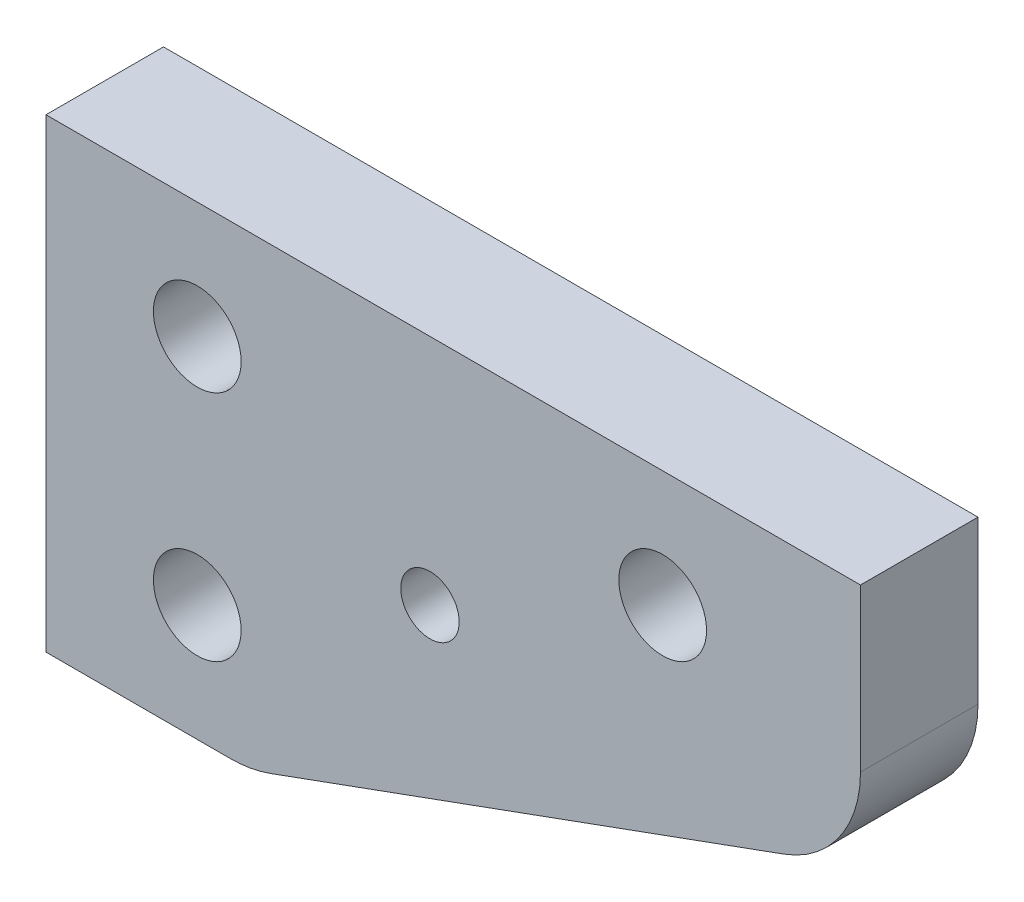
from build123d import *

# Parameters (mm, degrees)
SKETCH1_R           = 4.7879
SKETCH1_R_2         = 3.1877
BOSS_EXTRUDE1_DEPTH = 6.4135
FILLET1_R           = 12.7


with BuildPart() as part:
    # Sketch1 → Boss-Extrude1 (new body, symmetric)
    with BuildSketch(Plane.XY):
        Polygon((0, 0), (22.352, 0), (88.9, 24.22149115), (88.9, 50.8), (0, 50.8), align=None)
        with Locations((16.51, 12.7)):
            Circle(SKETCH1_R, mode=Mode.SUBTRACT)
        with Locations((16.51, 38.1)):
            Circle(SKETCH1_R, mode=Mode.SUBTRACT)
        with Locations((67.31, 38.1)):
            Circle(SKETCH1_R, mode=Mode.SUBTRACT)
        with Locations((41.91, 25.4)):
            Circle(SKETCH1_R_2, mode=Mode.SUBTRACT)
    extrude(amount=BOSS_EXTRUDE1_DEPTH, both=True)

    # Fillet1
    fillet1_edges = [part.edges().sort_by_distance(p)[0] for p in [
        (88.9, 24.22149115, 0),
        (22.352, 0, 0),
    ]]
    fillet(fillet1_edges, radius=FILLET1_R)


solid = part.part
